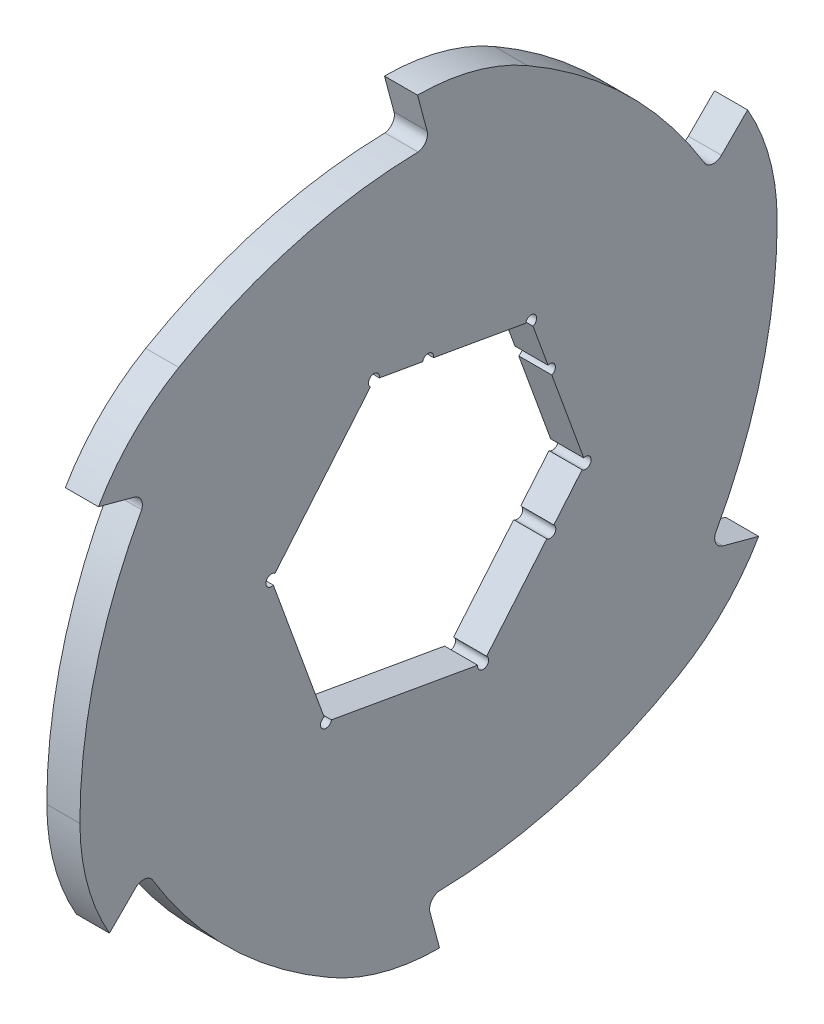
from build123d import *

# Parameters (mm, degrees)
SKETCH1_R                = 59
EXTRUDE1_DEPTH           = 3
EXTRUDE2_DEPTH           = 3
CIRPATTERN1_COUNT        = 6
F_2_0_2_DIAMETER_HOLE1_D = 2
F_2_0_2_DIAMETER_HOLE3_D = 2
CIRPATTERN2_COUNT        = 3
CIRPATTERN2_ANGLE        = 120


with BuildPart() as part:
    # Sketch1 → Extrude1 (new, symmetric)
    with BuildSketch(Plane(origin=(0, 0, 0), x_dir=(0, 0, -1), z_dir=(1, 0, 0))):
        Circle(SKETCH1_R)
        Polygon((18.592791334, 22.158025869), (-9.893017633, 27.180842557), (-28.485808967, 5.022816688), (-18.592791334, -22.158025869), (9.893017633, -27.180842557), (28.485808967, -5.022816688), align=None, mode=Mode.SUBTRACT)
    extrude(amount=EXTRUDE1_DEPTH, both=True)

    # Sketch2 → Extrude2 (add, symmetric)
    with BuildSketch(Plane(origin=(0, 0, 0), x_dir=(0, 0, -1), z_dir=(1, 0, 0))):
        with BuildLine():
            Line((-2, 67.961805723), (-0.262709442, 61.478149092))
            ThreePointArc((-0.262709442, 61.478149092), (-0.58620663, 59.77173183), (-2.122608272, 58.961805723))
            ThreePointArc((-2.122608272, 58.961805723), (28.679663449, 51.560419941), (51.21368579, 29.294340542))
            ThreePointArc((51.21368579, 29.294340542), (36.791707484, 48.186627241), (17.927108603, 62.644803614))
            ThreePointArc((17.927108603, 62.644803614), (8.312130826, 66.609702921), (-2, 67.961805723))
        make_face()
    extrude2 = extrude(amount=EXTRUDE2_DEPTH, both=True)

    # CirPattern1: Extrude2 ×6 about axis
    cirpattern1_axis = Axis((0, 0, 0), (1, 0, 0))
    for i in range(1, CIRPATTERN1_COUNT):
        add(extrude2.rotate(cirpattern1_axis, i * 360 / CIRPATTERN1_COUNT))

    # Ø2.0 (2) Diameter Hole1 (through all)
    with Locations(Plane(origin=(3, 0, 0), x_dir=(0, 0, -1), z_dir=(1, 0, 0))):
        with Locations((-9.893017633, 27.180842557), (18.592791334, 22.158025869), (28.485808967, -5.022816688), (9.893017633, -27.180842557), (-18.592791334, -22.158025869), (-28.485808967, 5.022816688)):
            Hole(F_2_0_2_DIAMETER_HOLE1_D / 2)

    # Ø2.0 (2) Diameter Hole3 (through all)
    with Locations(Plane(origin=(3, 0, 0), x_dir=(0, 0, -1), z_dir=(1, 0, 0))):
        with Locations((-0.069478726, 25.448687602)):
            f_2_0_2_diameter_hole3 = Hole(F_2_0_2_DIAMETER_HOLE3_D / 2)

    # CirPattern2: Ø2.0 (2) Diameter Hole3 ×3 about axis
    cirpattern2_axis = Axis((0, 0, 0), (-1, 0, 0))
    for i in range(1, CIRPATTERN2_COUNT):
        add(f_2_0_2_diameter_hole3.rotate(cirpattern2_axis, i * CIRPATTERN2_ANGLE / (CIRPATTERN2_COUNT - 1)), mode=Mode.SUBTRACT)


solid = part.part
